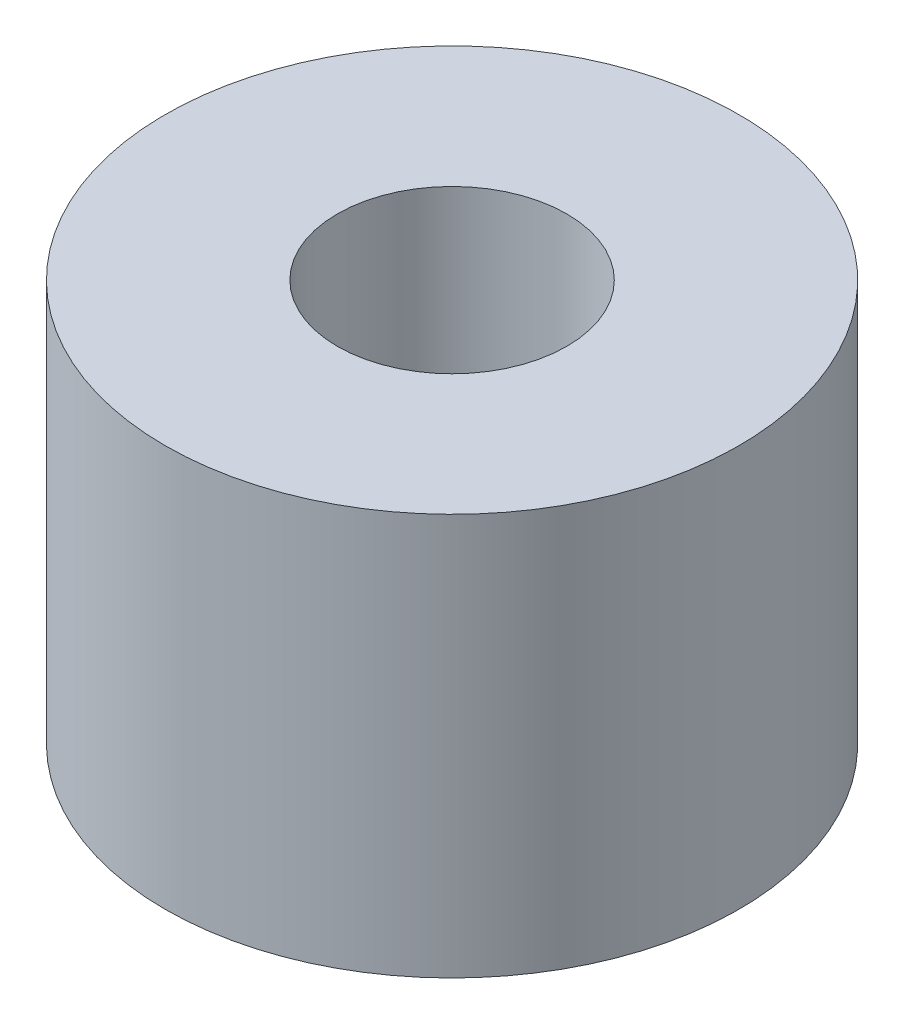
from build123d import *

# Parameters (mm, degrees)
ESQUISSE2_R             = 25
BOSS_EXTRU_1_DEPTH      = 35
ESQUISSE3_R             = 10
ENL_V_MAT_EXTRU_1_DEPTH = 35
TROU_TARAUD_M62_D       = 5
TROU_TARAUD_M62_DEPTH   = 20
TROU_TARAUD_M62_TIP     = 1.502151548


with BuildPart() as part:
    # Esquisse2 → Boss.-Extru.1 (new body)
    with BuildSketch(Plane(origin=(0, 0, 0), x_dir=(1, 0, 0), z_dir=(0, 1, 0))):
        with Locations(Location((0, 0, 0), (0, 0, 270))):  # turned: the seam where the file's is
            Circle(ESQUISSE2_R)
    extrude(amount=BOSS_EXTRU_1_DEPTH)

    # Esquisse3 → Enlèv. mat.-Extru.1 (cut)
    with BuildSketch(Plane(origin=(0, 35, 0), x_dir=(1, 0, 0), z_dir=(0, 1, 0))):
        with Locations(Location((0, 0, 0), (0, 0, 270))):  # turned: the seam where the file's is
            Circle(ESQUISSE3_R)
    extrude(amount=-ENL_V_MAT_EXTRU_1_DEPTH, mode=Mode.SUBTRACT)

    # Trou taraudé M62
    with Locations(Plane(origin=(0, 0, 0), x_dir=(-1, 0, 0), z_dir=(0, -1, 0))):
        with Locations((17.5, 0), (-8.74846, -15.156333581), (-8.753079729, 15.153666067)):
            Hole(TROU_TARAUD_M62_D / 2, depth=TROU_TARAUD_M62_DEPTH)
            with Locations((0, 0, -(TROU_TARAUD_M62_DEPTH + TROU_TARAUD_M62_TIP / 2))):  # 118° drill point
                Cone(0, TROU_TARAUD_M62_D / 2, TROU_TARAUD_M62_TIP, mode=Mode.SUBTRACT)


solid = part.part
